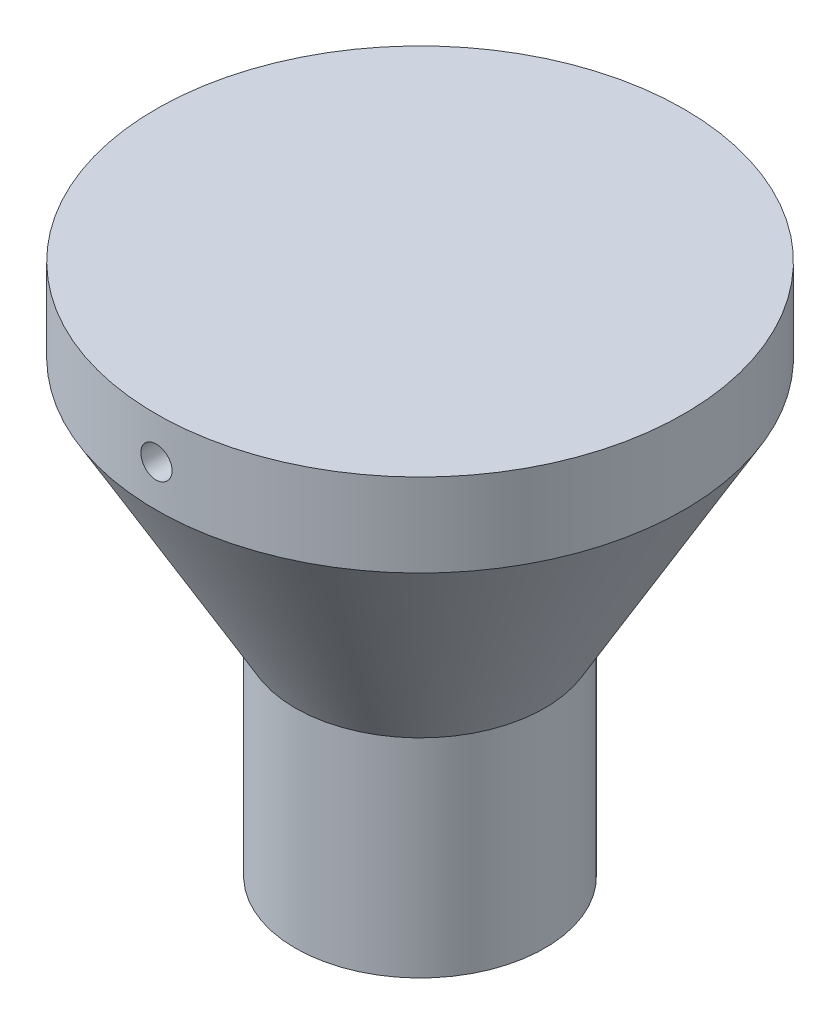
from build123d import *

# Parameters (mm, degrees)
SHELL1_T           = -7.5
SKETCH2_R          = 28.25
SKETCH2_R_2        = 24
CUT_EXTRUDE1_DEPTH = 2
SKETCH4_R          = 3.75
CUT_EXTRUDE2_DEPTH = 75


with BuildPart() as part:
    # Sketch1 → Revolve1 (revolve)
    with BuildSketch(Plane.XY, mode=Mode.PRIVATE) as revolve1_sk:
        Polygon((0, 0), (0, 88), (0, 128), (-63.486315613, 128), (-63.486315613, 108), (-30, 50), (-30, 0), align=None)
    revolve(revolve1_sk.sketch.rotate(Axis((0, 0, 0), (0, 1, 0)), 270), axis=Axis((0, 0, 0), (0, 1, 0)))

    # Shell1
    shell1_openings = [part.faces().sort_by_distance(p)[0] for p in [
        (0, 0, 0),
    ]]
    offset(amount=SHELL1_T, openings=shell1_openings, kind=Kind.INTERSECTION)

    # Sketch2 → Cut-Extrude1 (cut)
    with BuildSketch(Plane.XZ):
        with Locations(Location((0, 0, 0), (0, 0, 270))):
            Circle(SKETCH2_R)
        with Locations(Location((0, 0, 0), (0, 0, 270))):
            Circle(SKETCH2_R_2, mode=Mode.SUBTRACT)
    extrude(amount=-CUT_EXTRUDE1_DEPTH, mode=Mode.SUBTRACT)

    # Sketch4 → Cut-Extrude2 (cut, symmetric)
    with BuildSketch(Plane.XY):
        with Locations((0, 118)):
            Circle(SKETCH4_R)
    extrude(amount=CUT_EXTRUDE2_DEPTH, both=True, mode=Mode.SUBTRACT)


solid = part.part
